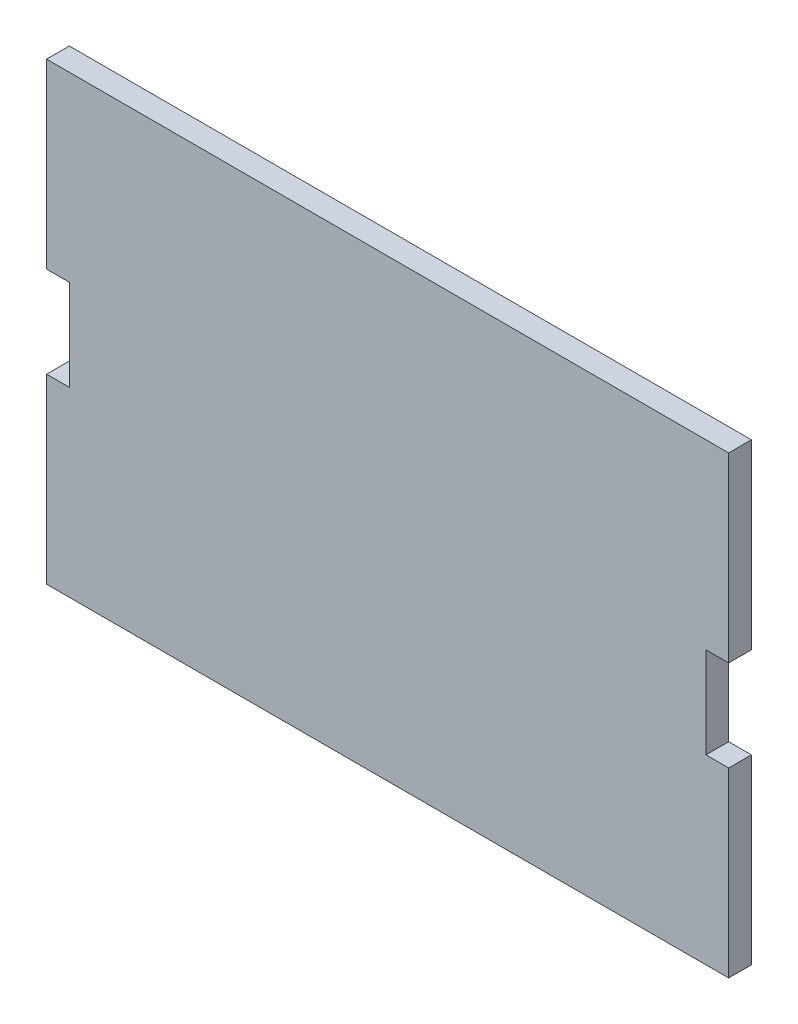
from build123d import *

# Parameters (mm, degrees)
SKIZZE1_W                       = 1500
SKIZZE1_H                       = 1000
AUFSATZ_LINEAR_AUSTRAGEN1_DEPTH = 50
SCHNITT_LINEAR_AUSTRAGEN1_REACH = 52
SKIZZE2_W                       = 50
SKIZZE2_H                       = 200
SCHNITT_LINEAR_AUSTRAGEN2_REACH = 52
SKIZZE3_W                       = 50
SKIZZE3_H                       = 200


with BuildPart() as part:
    # Skizze1 → Aufsatz-Linear austragen1 (new body)
    with BuildSketch(Plane.XY):
        with Locations((0, -500)):
            Rectangle(SKIZZE1_W, SKIZZE1_H)
    extrude(amount=AUFSATZ_LINEAR_AUSTRAGEN1_DEPTH)

    # Skizze2 → Schnitt-Linear austragen1 (cut, up to next)
    with BuildSketch(Plane.XY.offset(50), mode=Mode.PRIVATE) as schnitt_linear_austragen1_sk1:
        with Locations((-725, -500)):
            Rectangle(SKIZZE2_W, SKIZZE2_H)
    schnitt_linear_austragen1_tool1 = extrude(schnitt_linear_austragen1_sk1.sketch, amount=-SCHNITT_LINEAR_AUSTRAGEN1_REACH, mode=Mode.PRIVATE) & part.part
    add(schnitt_linear_austragen1_tool1.solids().sort_by_distance((-725, -500, 50))[0], mode=Mode.SUBTRACT)

    # Skizze3 → Schnitt-Linear austragen2 (cut, up to next)
    with BuildSketch(Plane.XY.offset(50), mode=Mode.PRIVATE) as schnitt_linear_austragen2_sk1:
        with Locations((725, -500)):
            Rectangle(SKIZZE3_W, SKIZZE3_H)
    schnitt_linear_austragen2_tool1 = extrude(schnitt_linear_austragen2_sk1.sketch, amount=-SCHNITT_LINEAR_AUSTRAGEN2_REACH, mode=Mode.PRIVATE) & part.part
    add(schnitt_linear_austragen2_tool1.solids().sort_by_distance((725, -500, 50))[0], mode=Mode.SUBTRACT)


solid = part.part
